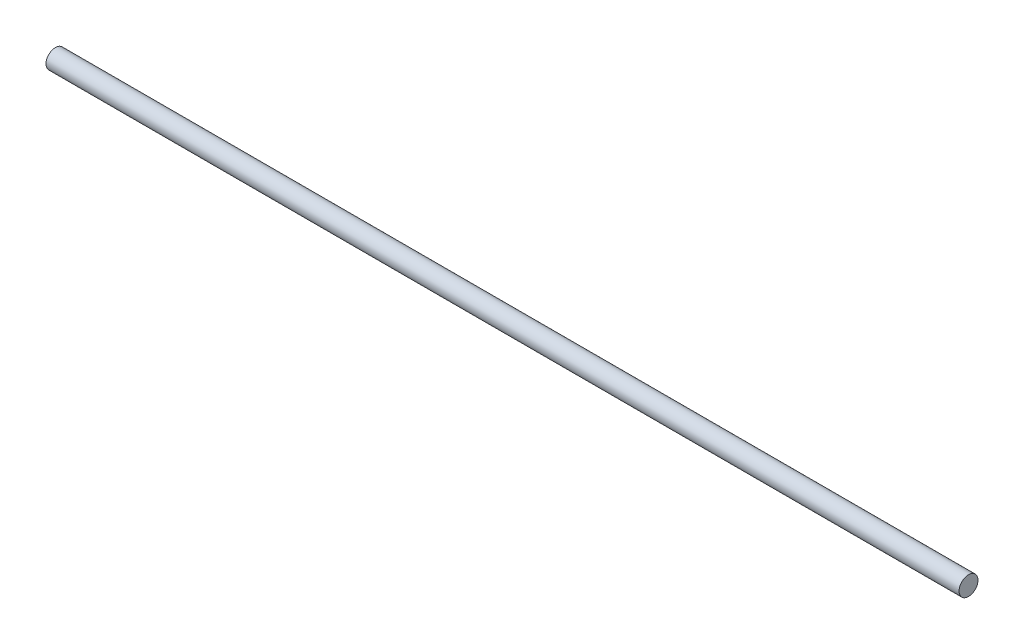
from build123d import *

# Parameters (mm, degrees)
SKETCH1_R           = 6.35
BOSS_EXTRUDE1_DEPTH = 306.3875


with BuildPart() as part:
    # Sketch1 → Boss-Extrude1 (new body, symmetric)
    with BuildSketch(Plane(origin=(0, 0, 0), x_dir=(0, 0, -1), z_dir=(1, 0, 0))):
        Circle(SKETCH1_R)
    extrude(amount=BOSS_EXTRUDE1_DEPTH, both=True)


solid = part.part
